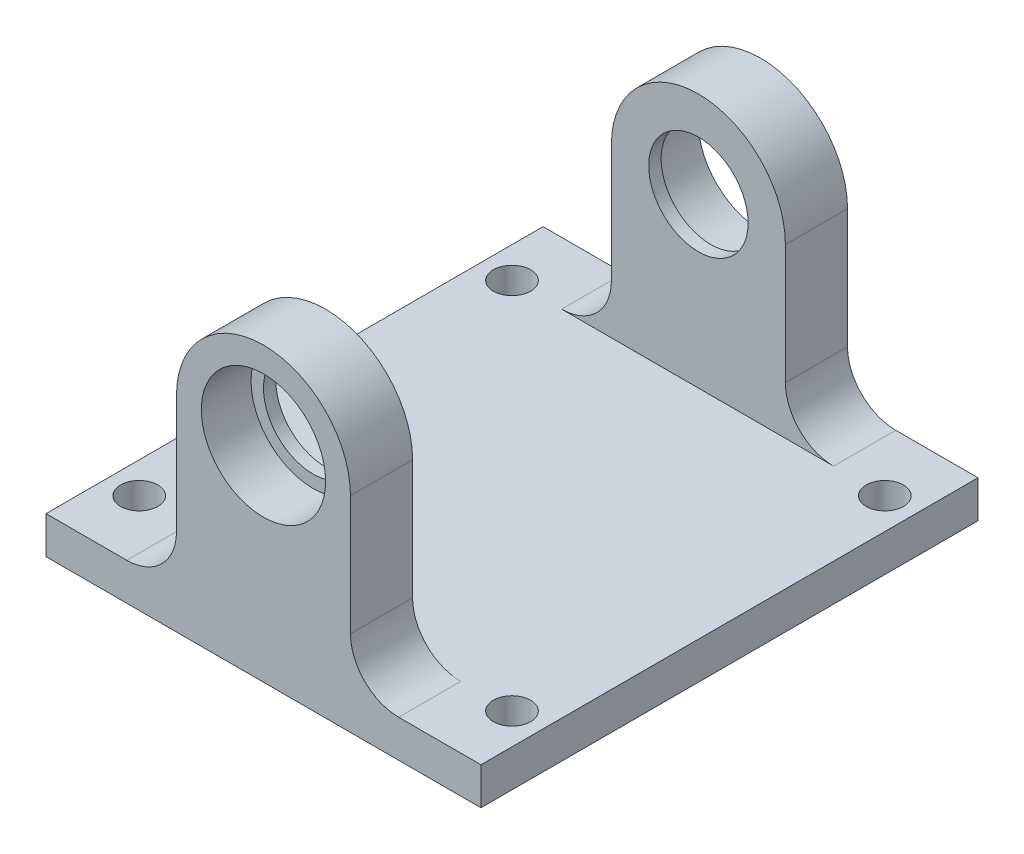
from build123d import *

# Parameters (mm, degrees)
CROQUIS1_W              = 35
CROQUIS1_H              = 40
CROQUIS1_R              = 1.5
SALIENTE_EXTRUIR1_DEPTH = 3
CROQUIS2_R              = 5
SALIENTE_EXTRUIR2_DEPTH = 40
CROQUIS3_W              = 27
CROQUIS3_H              = 30
CORTAR_EXTRUIR1_DEPTH   = 21.5
CROQUIS4_R              = 5
CROQUIS4_R_2            = 4
SALIENTE_EXTRUIR3_DEPTH = 1
CROQUIS5_R              = 5
CROQUIS5_R_2            = 4
SALIENTE_EXTRUIR4_DEPTH = 1


with BuildPart() as part:
    # Croquis1 → Saliente-Extruir1 (new body)
    with BuildSketch(Plane(origin=(0, 0, 0), x_dir=(1, 0, 0), z_dir=(0, 1, 0))):
        with Locations((17.5, 20)):
            Rectangle(CROQUIS1_W, CROQUIS1_H)
        with Locations((2.5, 35)):
            Circle(CROQUIS1_R, mode=Mode.SUBTRACT)
        with Locations((32.5, 35)):
            Circle(CROQUIS1_R, mode=Mode.SUBTRACT)
        with Locations((32.5, 5)):
            Circle(CROQUIS1_R, mode=Mode.SUBTRACT)
        with Locations((2.5, 5)):
            Circle(CROQUIS1_R, mode=Mode.SUBTRACT)
    extrude(amount=SALIENTE_EXTRUIR1_DEPTH)

    # Croquis2 → Saliente-Extruir2 (add)
    with BuildSketch(Plane.XY):
        with BuildLine():
            Line((24.5, 16.5), (24.5, 6.880942837))
            ThreePointArc((24.5, 6.880942837), (25.636701839, 4.136701839), (28.380942837, 3))
            Line((28.380942837, 3), (6.5, 3))
            ThreePointArc((6.5, 3), (9.328427125, 4.171572875), (10.5, 7))
            Line((10.5, 7), (10.5, 16.5))
            ThreePointArc((10.5, 16.5), (17.5, 23.5), (24.5, 16.5))
        make_face()
        with Locations((17.5, 16.5)):
            Circle(CROQUIS2_R, mode=Mode.SUBTRACT)
    extrude(amount=-SALIENTE_EXTRUIR2_DEPTH)

    # Croquis3 → Cortar-Extruir1 (cut, through all)
    with BuildSketch(Plane(origin=(0, 3, 0), x_dir=(1, 0, 0), z_dir=(0, 1, 0))):
        with Locations((17.5, 20)):
            Rectangle(CROQUIS3_W, CROQUIS3_H)
    extrude(amount=CORTAR_EXTRUIR1_DEPTH, mode=Mode.SUBTRACT)

    # Croquis4 → Saliente-Extruir3 (add)
    with BuildSketch(Plane.XY.offset(-35)):
        with Locations((17.5, 16.5)):
            Circle(CROQUIS4_R)
        with Locations((17.5, 16.5)):
            Circle(CROQUIS4_R_2, mode=Mode.SUBTRACT)
    extrude(amount=-SALIENTE_EXTRUIR3_DEPTH)

    # Croquis5 → Saliente-Extruir4 (add)
    with BuildSketch(Plane(origin=(0, 0, -5), x_dir=(-1, 0, 0), z_dir=(0, 0, -1))):
        with Locations((-17.5, 16.5)):
            Circle(CROQUIS5_R)
        with Locations((-17.5, 16.5)):
            Circle(CROQUIS5_R_2, mode=Mode.SUBTRACT)
    extrude(amount=-SALIENTE_EXTRUIR4_DEPTH)


solid = part.part
